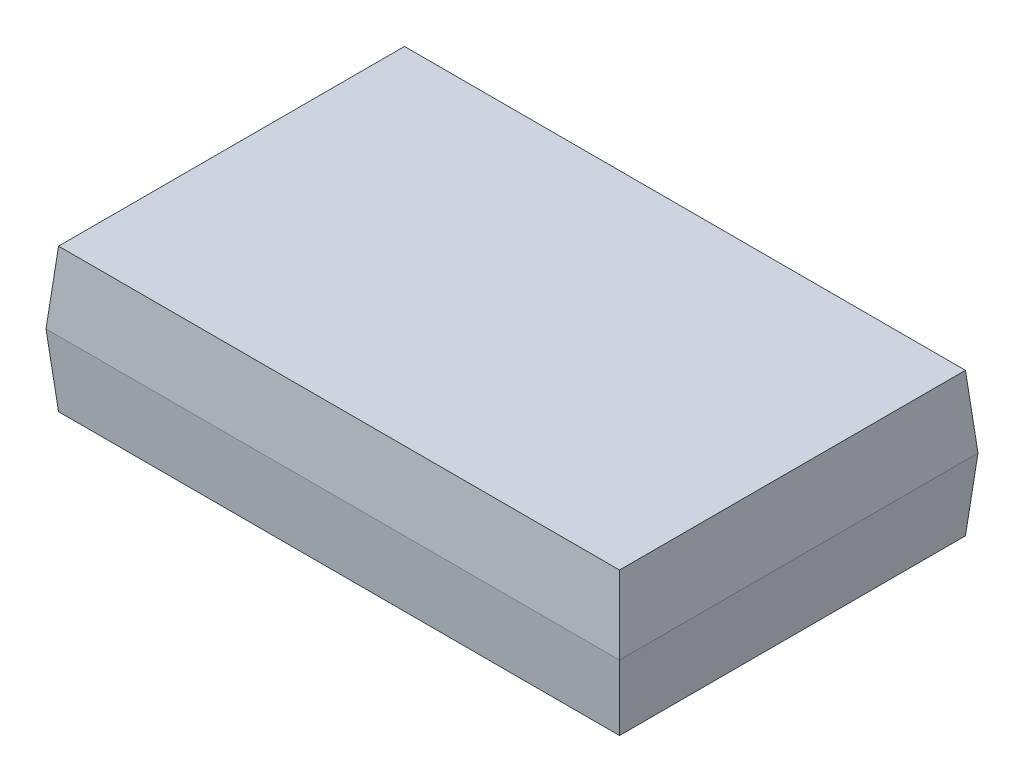
from build123d import *

# Parameters (mm, degrees)
SKETCH1_W                     = 4
SKETCH1_H                     = 2.5
BOSS_EXTRUDE1_DEPTH           = 0.5
BOSS_EXTRUDE1_TAPER           = 5
BOSS_EXTRUDE1_OTHER_WAY_DEPTH = 0.5
BOSS_EXTRUDE1_OTHER_WAY_TAPER = 5


with BuildPart() as part:
    # Sketch1 → Boss-Extrude1 (new body)
    with BuildSketch(Plane(origin=(0, 0, 0), x_dir=(1, 0, 0), z_dir=(0, 1, 0))):
        Rectangle(SKETCH1_W, SKETCH1_H)
    extrude(amount=BOSS_EXTRUDE1_DEPTH, taper=BOSS_EXTRUDE1_TAPER)

    # Sketch1 → Boss-Extrude1 other way (add)
    with BuildSketch(Plane(origin=(0, 0, 0), x_dir=(1, 0, 0), z_dir=(0, 1, 0))):
        Rectangle(SKETCH1_W, SKETCH1_H)
    extrude(amount=-BOSS_EXTRUDE1_OTHER_WAY_DEPTH, taper=BOSS_EXTRUDE1_OTHER_WAY_TAPER)


solid = part.part
